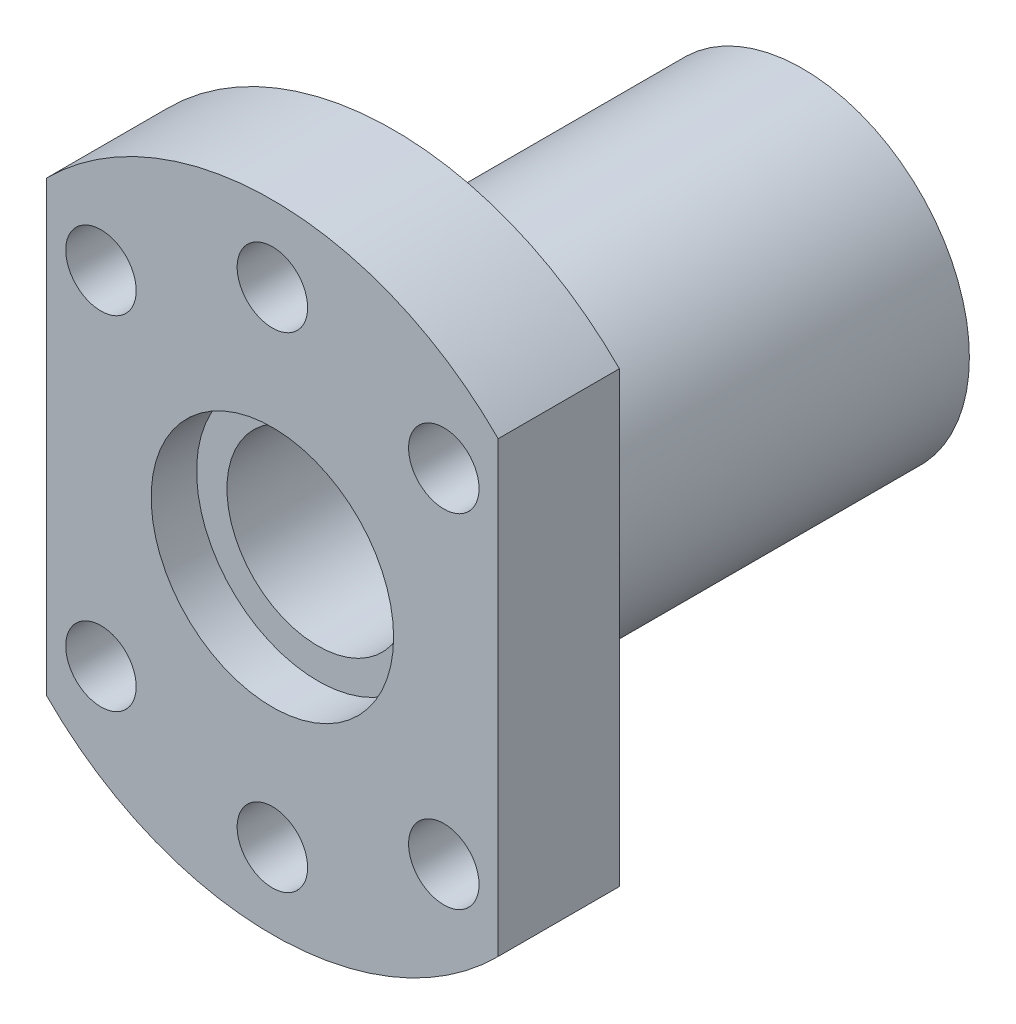
from build123d import *

# Parameters (mm, degrees)
SKETCH2_W               = 6.1
SKETCH2_H               = 8
CUT_EXTRUDE1_DEPTH      = 22
CUT_EXTRUDE1_DEPTH_BACK = 22
SKETCH3_R               = 2.325
CUT_EXTRUDE2_DEPTH      = 10


with BuildPart() as part:
    # Sketch1 → Revolve1 (revolve)
    with BuildSketch(Plane(origin=(0, 0, 0), x_dir=(0, 0, -1), z_dir=(1, 0, 0))):
        Polygon((14.5, 6), (-14.5, 6), (-14.5, 8), (-17.5, 8), (-17.5, 21), (-9.5, 21), (-9.5, 11), (17.5, 11), (17.5, 8), (14.5, 8), align=None)
    revolve(axis=Axis((0, 0, 27), (0, 0, -1)))

    # Sketch2 → Cut-Extrude1 (cut, two sides)
    with BuildSketch(Plane(origin=(0, 0, 0), x_dir=(1, 0, 0), z_dir=(0, 1, 0))) as cut_extrude1_sk:
        with Locations((-17.95, -13.5)):
            Rectangle(SKETCH2_W, SKETCH2_H)
        with Locations((17.95, -13.5)):
            Rectangle(SKETCH2_W, SKETCH2_H)
    extrude(amount=CUT_EXTRUDE1_DEPTH, mode=Mode.SUBTRACT)
    extrude(cut_extrude1_sk.sketch, amount=-CUT_EXTRUDE1_DEPTH_BACK, mode=Mode.SUBTRACT)

    # Sketch3 → Cut-Extrude2 (cut)
    with BuildSketch(Plane.XY.offset(17.5)):
        with Locations((0, 16)):
            Circle(SKETCH3_R)
        with Locations((11.313708499, 11.313708499)):
            Circle(SKETCH3_R)
        with Locations((11.313708499, -11.313708499)):
            Circle(SKETCH3_R)
        with Locations((0, -16)):
            Circle(SKETCH3_R)
        with Locations((-11.313708499, -11.313708499)):
            Circle(SKETCH3_R)
        with Locations((-11.313708499, 11.313708499)):
            Circle(SKETCH3_R)
    extrude(amount=-CUT_EXTRUDE2_DEPTH, mode=Mode.SUBTRACT)


solid = part.part
